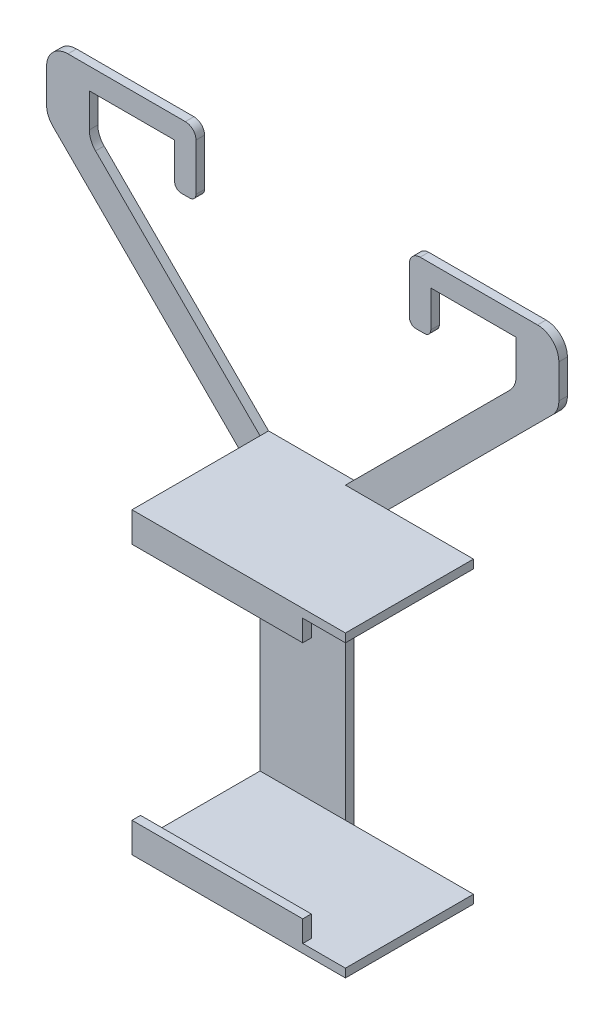
from build123d import *

# Parameters (mm, degrees)
BOSS_EXTRUDE1_DEPTH   = 2
BOSS_EXTRUDE1_2_DEPTH = 2
BASE_W                = 20
BASE_H                = 70
BOSS_EXTRUDE2_DEPTH   = 2
SKETCH10_W            = 50
SKETCH10_H            = 30
BOSS_EXTRUDE3_DEPTH   = 2
SKETCH9_W             = 50
SKETCH9_H             = 30
BOSS_EXTRUDE4_DEPTH   = 2
SKETCH11_W            = 40
SKETCH11_H            = 5
BOSS_EXTRUDE5_DEPTH   = 2


with BuildPart() as part:
    # hook → Boss-Extrude1 (new body)
    with BuildSketch(Plane.XY):
        with BuildLine():
            Line((-10, 35), (-10, 25))
            Line((-10, 25), (-58.535533906, 73.535533906))
            ThreePointArc((-58.535533906, 73.535533906), (-59.619397663, 75.15765065), (-60, 77.071067812))
            Line((-60, 77.071067812), (-60, 85))
            ThreePointArc((-60, 85), (-58.535533906, 88.535533906), (-55, 90))
            Line((-55, 90), (-27.5, 90))
            ThreePointArc((-27.5, 90), (-25.732233047, 89.267766953), (-25, 87.5))
            Line((-25, 87.5), (-24.999999999, 76.499999999))
            ThreePointArc((-24.999999999, 76.499999999), (-25.439339828, 75.439339828), (-26.499999999, 74.999999999))
            Line((-26.499999999, 74.999999999), (-28.499999999, 74.999999999))
            ThreePointArc((-28.499999999, 74.999999999), (-29.560660171, 75.439339828), (-29.999999999, 76.499999999))
            Line((-29.999999999, 76.499999999), (-29.999999999, 84.999999999))
            Line((-29.999999999, 84.999999999), (-49.999999999, 84.999999999))
            Line((-49.999999999, 84.999999999), (-50, 77.071067812))
            ThreePointArc((-50, 77.071067812), (-49.619397663, 75.15765065), (-48.535533906, 73.535533906))
            Line((-48.535533906, 73.535533906), (-10, 35))
        make_face()
    extrude(amount=-BOSS_EXTRUDE1_DEPTH)



with BuildPart() as body_2:
    # hook → Boss-Extrude1 2 (new body)
    with BuildSketch(Plane.XY):
        with BuildLine():
            Line((48.535533906, 73.535533906), (10, 35))
            Line((10, 35), (10, 25))
            Line((10, 25), (58.535533906, 73.535533906))
            ThreePointArc((58.535533906, 73.535533906), (59.619397663, 75.15765065), (60, 77.071067812))
            Line((60, 77.071067812), (60, 85))
            ThreePointArc((60, 85), (58.535533906, 88.535533906), (55, 90))
            Line((55, 90), (27.5, 90))
            ThreePointArc((27.5, 90), (25.732233047, 89.267766953), (25, 87.5))
            Line((25, 87.5), (24.999999999, 76.499999999))
            ThreePointArc((24.999999999, 76.499999999), (25.439339828, 75.439339828), (26.499999999, 74.999999999))
            Line((26.499999999, 74.999999999), (28.499999999, 74.999999999))
            ThreePointArc((28.499999999, 74.999999999), (29.560660171, 75.439339828), (29.999999999, 76.499999999))
            Line((29.999999999, 76.499999999), (29.999999999, 84.999999999))
            Line((29.999999999, 84.999999999), (49.999999999, 84.999999999))
            Line((49.999999999, 84.999999999), (50, 77.071067812))
            ThreePointArc((50, 77.071067812), (49.619397663, 75.15765065), (48.535533906, 73.535533906))
        make_face()
    extrude(amount=-BOSS_EXTRUDE1_2_DEPTH)


with BuildPart() as part_1:
    add(part.part)

    add(body_2.part)  # Boss-Extrude2 merges body 2
    # base → Boss-Extrude2 (add)
    with BuildSketch(Plane.XY):
        Rectangle(BASE_W, BASE_H)
    extrude(amount=-BOSS_EXTRUDE2_DEPTH)

    # Sketch9 → Boss-Extrude4 (add)
    with BuildSketch(Plane(origin=(0, 35, 0), x_dir=(1, 0, 0), z_dir=(0, 1, 0))):
        with Locations((15, -15)):
            Rectangle(SKETCH9_W, SKETCH9_H)
    extrude(amount=-BOSS_EXTRUDE4_DEPTH)



with BuildPart() as body_2_2:
    # Sketch10 → Boss-Extrude3 (new body)
    with BuildSketch(Plane(origin=(0, -35, 0), x_dir=(1, 0, 0), z_dir=(0, 1, 0))):
        with Locations((15, -15)):
            Rectangle(SKETCH10_W, SKETCH10_H)
    extrude(amount=BOSS_EXTRUDE3_DEPTH)


with BuildPart() as part_2:
    add(part_1.part)

    add(body_2_2.part)  # Boss-Extrude5 merges body 2 2
    # Sketch11 → Boss-Extrude5 (add)
    with BuildSketch(Plane.XY.offset(30)):
        with Locations((10, -30.5)):
            Rectangle(SKETCH11_W, SKETCH11_H)
        with Locations((10, 30.5)):
            Rectangle(SKETCH11_W, SKETCH11_H)
    extrude(amount=-BOSS_EXTRUDE5_DEPTH)


solid = part_2.part
